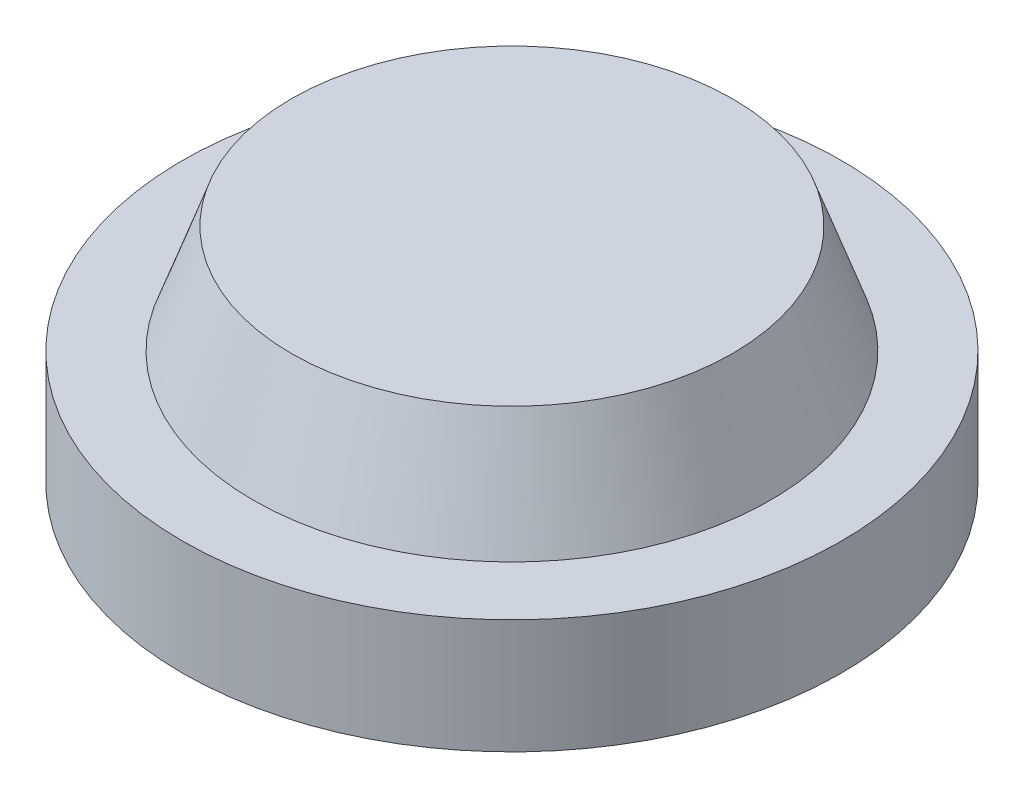
from build123d import *


with BuildPart() as part:
    # Sketch2 → Revolve1 (revolve)
    with BuildSketch(Plane.XY):
        Polygon((0, 0), (30.25, 0), (30.25, 10.5), (23.75, 10.5), (20.25, 20.404867257), (0, 20.404867257), align=None)
    revolve(axis=Axis((0, 20.404867257, 0), (0, -1, 0)))


solid = part.part
